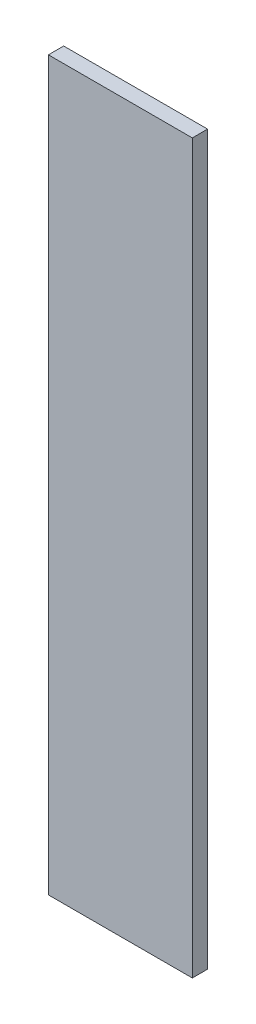
from build123d import *

# Parameters (mm, degrees)
BOSS_EXTRUDE1_DEPTH = 3


with BuildPart() as part:
    # Sketch1 → Boss-Extrude1 (new body)
    with BuildSketch(Plane.XY):
        Polygon((-100.466480089, 0), (-100.466480089, 140), (-100.466480089, 143), (-72.182208841, 143), (-72.182208841, 0), align=None)
    extrude(amount=BOSS_EXTRUDE1_DEPTH)


solid = part.part
